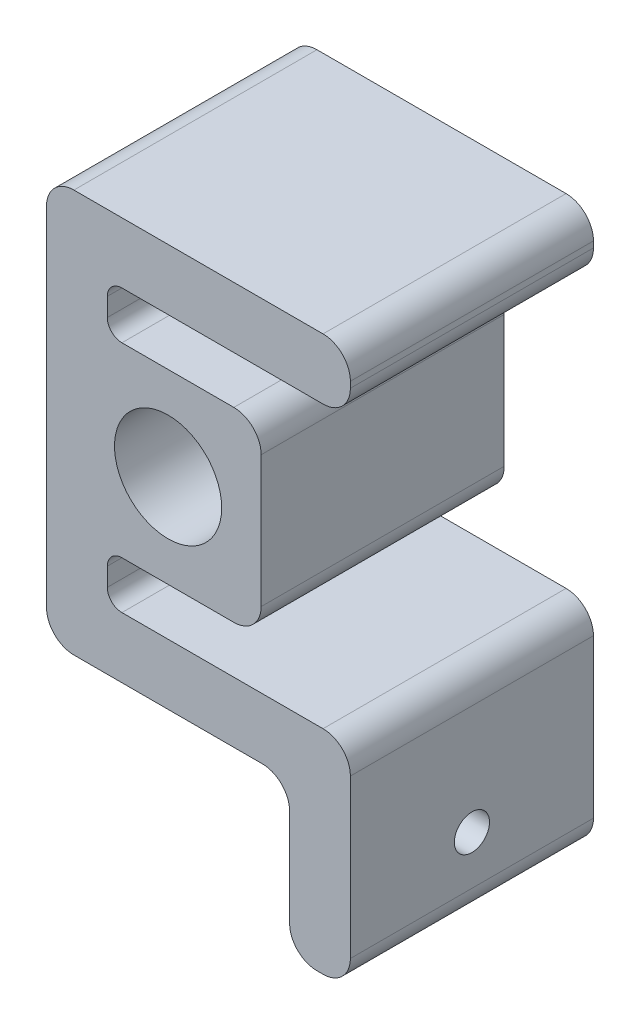
from build123d import *

# Parameters (mm, degrees)
SKETCH1_R           = 11.2
BOSS_EXTRUDE1_DEPTH = 50.8
SKETCH2_R           = 3.675
CUT_EXTRUDE1_DEPTH  = 50.8


with BuildPart() as part:
    # Sketch1 → Boss-Extrude1 (new body)
    with BuildSketch(Plane.XY):
        with BuildLine():
            Line((-25.4, -36.364999962), (-25.4, 36.365))
            ThreePointArc((-25.4, 36.365), (-23.726115254, 40.406115254), (-19.685, 42.08))
            Line((-19.685, 42.08), (32.385, 42.08))
            ThreePointArc((32.385, 42.08), (36.426115254, 40.406115254), (38.1, 36.365))
            Line((38.1, 36.365), (38.1, 35.095))
            ThreePointArc((38.1, 35.095), (36.426115254, 31.053884746), (32.385, 29.38))
            Line((32.385, 29.38), (-9.652, 29.38))
            ThreePointArc((-9.652, 29.38), (-11.807261469, 28.487261469), (-12.7, 26.332))
            Line((-12.7, 26.332), (-12.7, 22.503))
            ThreePointArc((-12.7, 22.503), (-11.807261469, 20.347738531), (-9.652, 19.455))
            Line((-9.652, 19.455), (0, 19.455))
            Line((0, 19.455), (13.74, 19.455))
            ThreePointArc((13.74, 19.455), (17.781115254, 17.781115254), (19.455, 13.74))
            Line((19.455, 13.74), (19.455, 0))
            Line((19.455, 0), (19.455, -13.74))
            ThreePointArc((19.455, -13.74), (17.781115254, -17.781115254), (13.74, -19.455))
            Line((13.74, -19.455), (0, -19.455))
            Line((0, -19.455), (-9.652, -19.455))
            ThreePointArc((-9.652, -19.455), (-11.807261469, -20.347738531), (-12.7, -22.503))
            Line((-12.7, -22.503), (-12.7, -26.331999962))
            ThreePointArc((-12.7, -26.331999962), (-11.807261469, -28.487261431), (-9.652, -29.379999962))
            Line((-9.652, -29.379999962), (32.385, -29.379999962))
            ThreePointArc((32.385, -29.379999962), (36.426115254, -31.053884708), (38.1, -35.094999962))
            Line((38.1, -35.094999962), (38.1, -68.114999962))
            ThreePointArc((38.1, -68.114999962), (36.426115254, -72.156115216), (32.385, -73.829999962))
            Line((32.385, -73.829999962), (31.115, -73.829999962))
            ThreePointArc((31.115, -73.829999962), (27.073884746, -72.156115216), (25.4, -68.114999962))
            Line((25.4, -68.114999962), (25.4, -47.794999962))
            ThreePointArc((25.4, -47.794999962), (23.726115254, -43.753884708), (19.685, -42.079999962))
            Line((19.685, -42.079999962), (-19.685, -42.079999962))
            ThreePointArc((-19.685, -42.079999962), (-23.726115254, -40.406115216), (-25.4, -36.364999962))
        make_face()
        Circle(SKETCH1_R, mode=Mode.SUBTRACT)
    extrude(amount=BOSS_EXTRUDE1_DEPTH)

    # Sketch2 → Cut-Extrude1 (cut)
    with BuildSketch(Plane(origin=(25.4, 0, 0), x_dir=(0, 0, -1), z_dir=(1, 0, 0))):
        with Locations((-25.4, -57.954999962)):
            Circle(SKETCH2_R)
    extrude(amount=CUT_EXTRUDE1_DEPTH, mode=Mode.SUBTRACT)


solid = part.part
